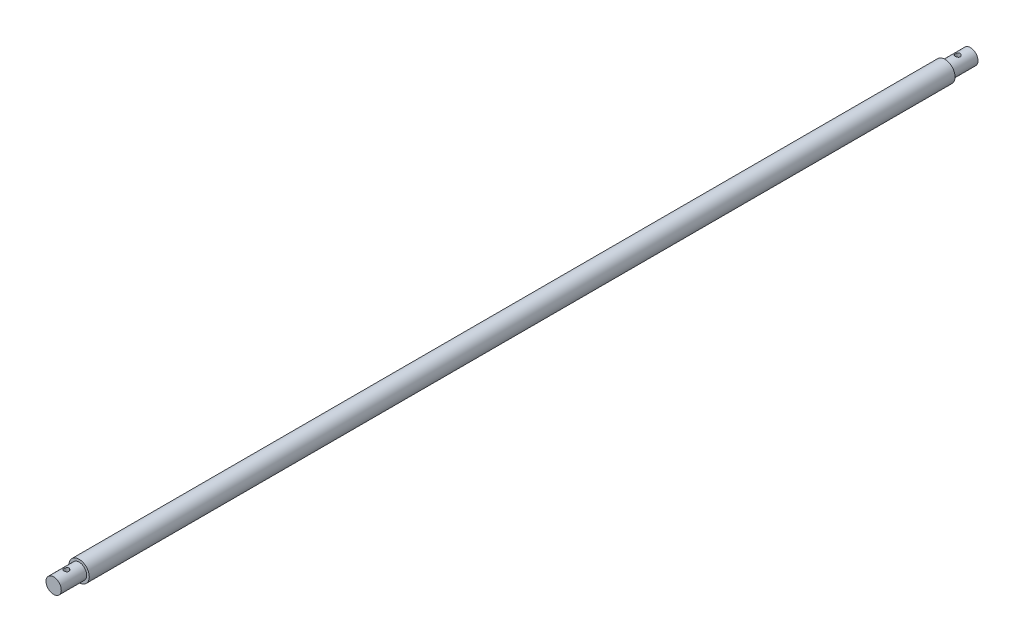
from build123d import *

# Parameters (mm, degrees)
SKETCH1_R               = 4
BOSS_EXTRUDE1_DEPTH     = 350
SKETCH2_R               = 3
BOSS_EXTRUDE2_DEPTH     = 10
SKETCH3_R               = 1
CUT_EXTRUDE1_DEPTH      = 3
SKETCH5_R               = 4
SKETCH5_R_2             = 3
CUT_EXTRUDE3_DEPTH      = 10
SKETCH6_R               = 1
CUT_EXTRUDE4_DEPTH      = 5
CUT_EXTRUDE4_DEPTH_BACK = 5


with BuildPart() as part:
    # Sketch1 → Boss-Extrude1 (new body)
    with BuildSketch(Plane.XY):
        Circle(SKETCH1_R)
    extrude(amount=BOSS_EXTRUDE1_DEPTH)

    # Sketch2 → Boss-Extrude2 (add)
    with BuildSketch(Plane.XY.offset(350)):
        Circle(SKETCH2_R)
    extrude(amount=BOSS_EXTRUDE2_DEPTH)

    # Sketch3 → Cut-Extrude1 (cut, symmetric)
    with BuildSketch(Plane(origin=(0, 0, 0), x_dir=(1, 0, 0), z_dir=(0, 1, 0))):
        with Locations((0, -355)):
            Circle(SKETCH3_R)
    extrude(amount=CUT_EXTRUDE1_DEPTH, both=True, mode=Mode.SUBTRACT)

    # Sketch5 → Cut-Extrude3 (cut)
    with BuildSketch(Plane(origin=(0, 0, 0), x_dir=(-1, 0, 0), z_dir=(0, 0, -1))):
        Circle(SKETCH5_R)
        Circle(SKETCH5_R_2, mode=Mode.SUBTRACT)
    extrude(amount=-CUT_EXTRUDE3_DEPTH, mode=Mode.SUBTRACT)

    # Sketch6 → Cut-Extrude4 (cut, two sides)
    with BuildSketch(Plane(origin=(0, 0, 0), x_dir=(1, 0, 0), z_dir=(0, 1, 0))) as cut_extrude4_sk:
        with Locations((0, -5)):
            Circle(SKETCH6_R)
    extrude(amount=CUT_EXTRUDE4_DEPTH, mode=Mode.SUBTRACT)
    extrude(cut_extrude4_sk.sketch, amount=-CUT_EXTRUDE4_DEPTH_BACK, mode=Mode.SUBTRACT)


solid = part.part
